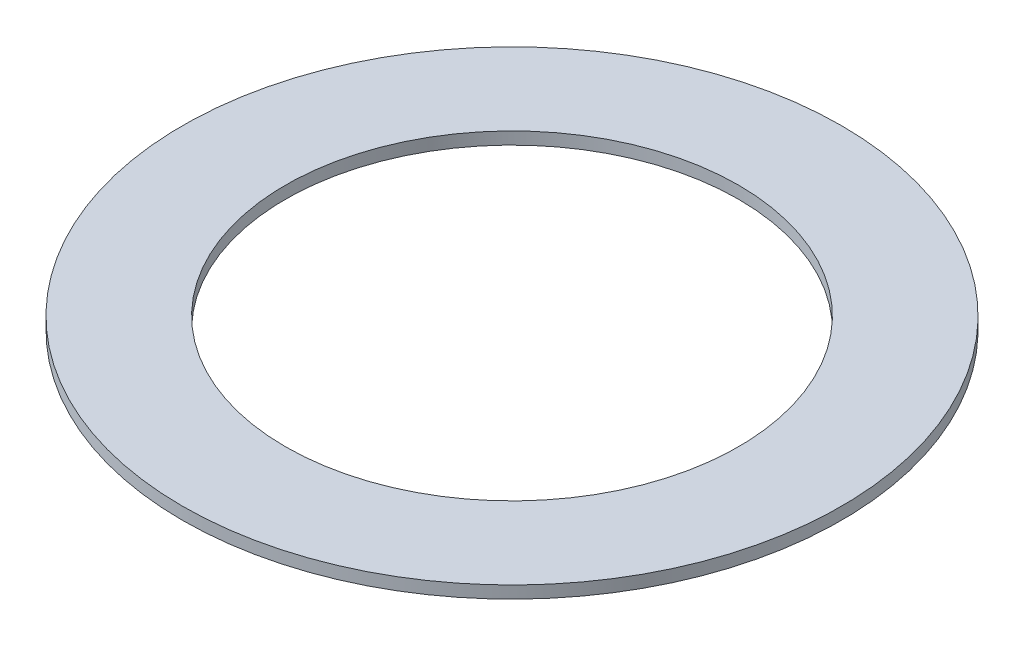
from build123d import *

# Parameters (mm, degrees)
SKETCH1_R           = 9.5504
SKETCH1_R_2         = 6.5659
BOSS_EXTRUDE1_DEPTH = 0.3556


with BuildPart() as part:
    # Sketch1 → Boss-Extrude1 (new body)
    with BuildSketch(Plane(origin=(0, 0, 0), x_dir=(1, 0, 0), z_dir=(0, 1, 0))):
        Circle(SKETCH1_R)
        Circle(SKETCH1_R_2, mode=Mode.SUBTRACT)
    extrude(amount=BOSS_EXTRUDE1_DEPTH)


solid = part.part
